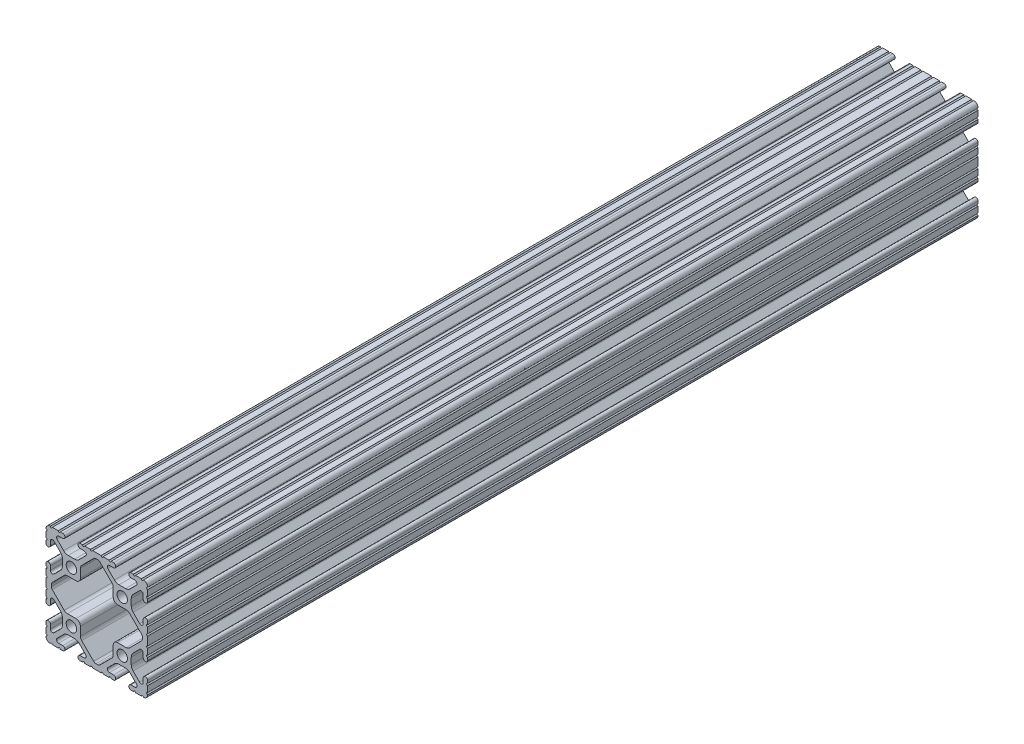
from build123d import *

# Parameters (mm, degrees)
SKETCH1_R      = 2.6035
EXTRUDE1_DEPTH = 415


with BuildPart() as part:
    # Sketch1 → Extrude1 (new body)
    with BuildSketch(Plane.XY):
        with BuildLine():
            Line((910.156254844, 557.093818315), (905.889054844, 557.093818315))
            ThreePointArc((905.889054844, 557.093818315), (905.381054844, 556.585818315), (904.873054844, 557.093818315))
            Line((904.873054844, 557.093818315), (901.926654844, 557.093818315))
            ThreePointArc((901.926654844, 557.093818315), (901.418654844, 556.585818315), (900.910654844, 557.093818315))
            Line((900.910654844, 557.093818315), (899.678754844, 557.093818315))
            ThreePointArc((899.678754844, 557.093818315), (898.573854844, 555.988918315), (899.678754844, 554.884018315))
            Line((899.678754844, 554.884018315), (901.727603922, 554.884018315))
            ThreePointArc((901.727603922, 554.884018315), (902.668315674, 554.237585095), (902.477834304, 553.112182342))
            Line((902.477834304, 553.112182342), (899.193915354, 549.828164729))
            ThreePointArc((899.193915354, 549.828164729), (898.163859528, 549.139886645), (896.948817599, 548.898195034))
            Line((896.948817599, 548.898195034), (893.696410281, 548.898195034))
            ThreePointArc((893.696410281, 548.898195034), (892.481371808, 549.139885213), (891.451317818, 549.828159437))
            Line((891.451317818, 549.828159437), (888.167597463, 553.111962966))
            ThreePointArc((888.167597463, 553.111962966), (887.978324963, 554.240284421), (888.924126242, 554.884018315))
            Line((888.924126242, 554.884018315), (890.966554844, 554.884018315))
            ThreePointArc((890.966554844, 554.884018315), (892.071454844, 555.988918315), (890.966554844, 557.093818315))
            Line((890.966554844, 557.093818315), (889.734654844, 557.093818315))
            ThreePointArc((889.734654844, 557.093818315), (889.226654844, 556.585818315), (888.718654844, 557.093818315))
            Line((888.718654844, 557.093818315), (885.772254844, 557.093818315))
            ThreePointArc((885.772254844, 557.093818315), (885.264254844, 556.585818315), (884.756254844, 557.093818315))
            Line((884.756254844, 557.093818315), (884.730854844, 557.093818315))
            ThreePointArc((884.730854844, 557.093818315), (883.240132328, 556.476340831), (882.622654844, 554.985618315))
            Line((882.622654844, 554.985618315), (882.622654844, 554.960218315))
            ThreePointArc((882.622654844, 554.960218315), (883.130654844, 554.452218315), (882.622654844, 553.944218315))
            Line((882.622654844, 553.944218315), (882.622654844, 550.997818315))
            ThreePointArc((882.622654844, 550.997818315), (883.130654844, 550.489818315), (882.622654844, 549.981818315))
            Line((882.622654844, 549.981818315), (882.622654844, 548.749918315))
            ThreePointArc((882.622654844, 548.749918315), (883.727554844, 547.645018315), (884.832454844, 548.749918315))
            Line((884.832454844, 548.749918315), (884.832454844, 550.798767394))
            ThreePointArc((884.832454844, 550.798767394), (885.478888064, 551.739479145), (886.604290816, 551.548997776))
            Line((886.604290816, 551.548997776), (889.888308429, 548.265078825))
            ThreePointArc((889.888308429, 548.265078825), (890.576586514, 547.235022999), (890.818278124, 546.01998107))
            Line((890.818278124, 546.01998107), (890.818278124, 542.767573752))
            ThreePointArc((890.818278124, 542.767573752), (890.576587946, 541.552535279), (889.888313721, 540.522481289))
            Line((889.888313721, 540.522481289), (886.604510192, 537.238760934))
            ThreePointArc((886.604510192, 537.238760934), (885.476188737, 537.049488434), (884.832454844, 537.995289713))
            Line((884.832454844, 537.995289713), (884.832454844, 540.037718315))
            ThreePointArc((884.832454844, 540.037718315), (883.727554844, 541.142618315), (882.622654844, 540.037718315))
            Line((882.622654844, 540.037718315), (882.622654844, 538.805818315))
            ThreePointArc((882.622654844, 538.805818315), (883.130654844, 538.297818315), (882.622654844, 537.789818315))
            Line((882.622654844, 537.789818315), (882.622654844, 534.843418315))
            ThreePointArc((882.622654844, 534.843418315), (883.130654844, 534.335418315), (882.622654844, 533.827418315))
            Line((882.622654844, 533.827418315), (882.622654844, 529.560218315))
            ThreePointArc((882.622654844, 529.560218315), (883.130654844, 529.052218315), (882.622654844, 528.544218315))
            Line((882.622654844, 528.544218315), (882.622654844, 525.597818315))
            ThreePointArc((882.622654844, 525.597818315), (883.130654844, 525.089818315), (882.622654844, 524.581818315))
            Line((882.622654844, 524.581818315), (882.622654844, 523.349918315))
            ThreePointArc((882.622654844, 523.349918315), (883.727554844, 522.245018315), (884.832454844, 523.349918315))
            Line((884.832454844, 523.349918315), (884.832454844, 525.398767394))
            ThreePointArc((884.832454844, 525.398767394), (885.478888064, 526.339479145), (886.604290816, 526.148997776))
            Line((886.604290816, 526.148997776), (889.888308429, 522.865078825))
            ThreePointArc((889.888308429, 522.865078825), (890.576586514, 521.835022999), (890.818278124, 520.61998107))
            Line((890.818278124, 520.61998107), (890.818278124, 517.367573752))
            ThreePointArc((890.818278124, 517.367573752), (890.576587946, 516.152535279), (889.888313721, 515.122481289))
            Line((889.888313721, 515.122481289), (886.604510192, 511.838760934))
            ThreePointArc((886.604510192, 511.838760934), (885.476188737, 511.649488434), (884.832454844, 512.595289713))
            Line((884.832454844, 512.595289713), (884.832454844, 514.637718315))
            ThreePointArc((884.832454844, 514.637718315), (883.727554844, 515.742618315), (882.622654844, 514.637718315))
            Line((882.622654844, 514.637718315), (882.622654844, 513.405818315))
            ThreePointArc((882.622654844, 513.405818315), (883.130654844, 512.897818315), (882.622654844, 512.389818315))
            Line((882.622654844, 512.389818315), (882.622654844, 509.443418315))
            ThreePointArc((882.622654844, 509.443418315), (883.130654844, 508.935418315), (882.622654844, 508.427418315))
            Line((882.622654844, 508.427418315), (882.622654844, 508.402018315))
            ThreePointArc((882.622654844, 508.402018315), (883.240132328, 506.911295799), (884.730854844, 506.293818315))
            Line((884.730854844, 506.293818315), (884.756254844, 506.293818315))
            ThreePointArc((884.756254844, 506.293818315), (885.264254844, 506.801818315), (885.772254844, 506.293818315))
            Line((885.772254844, 506.293818315), (888.718654844, 506.293818315))
            ThreePointArc((888.718654844, 506.293818315), (889.226654844, 506.801818315), (889.734654844, 506.293818315))
            Line((889.734654844, 506.293818315), (890.966554844, 506.293818315))
            ThreePointArc((890.966554844, 506.293818315), (892.071454844, 507.398718315), (890.966554844, 508.503618315))
            Line((890.966554844, 508.503618315), (888.917705765, 508.503618315))
            ThreePointArc((888.917705765, 508.503618315), (887.976994014, 509.150051535), (888.167475383, 510.275454288))
            Line((888.167475383, 510.275454288), (891.451394334, 513.5594719))
            ThreePointArc((891.451394334, 513.5594719), (892.481450159, 514.247749985), (893.696492089, 514.489441595))
            Line((893.696492089, 514.489441595), (896.948899407, 514.489441595))
            ThreePointArc((896.948899407, 514.489441595), (898.163937879, 514.247751417), (899.19399187, 513.559477193))
            Line((899.19399187, 513.559477193), (902.477712224, 510.275673663))
            ThreePointArc((902.477712224, 510.275673663), (902.666984724, 509.147352209), (901.721183446, 508.503618315))
            Line((901.721183446, 508.503618315), (899.678754844, 508.503618315))
            ThreePointArc((899.678754844, 508.503618315), (898.573854844, 507.398718315), (899.678754844, 506.293818315))
            Line((899.678754844, 506.293818315), (900.910654844, 506.293818315))
            ThreePointArc((900.910654844, 506.293818315), (901.418654844, 506.801818315), (901.926654844, 506.293818315))
            Line((901.926654844, 506.293818315), (904.873054844, 506.293818315))
            ThreePointArc((904.873054844, 506.293818315), (905.381054844, 506.801818315), (905.889054844, 506.293818315))
            Line((905.889054844, 506.293818315), (910.156254844, 506.293818315))
            ThreePointArc((910.156254844, 506.293818315), (910.664254844, 506.801818315), (911.172254844, 506.293818315))
            Line((911.172254844, 506.293818315), (914.118654844, 506.293818315))
            ThreePointArc((914.118654844, 506.293818315), (914.626654844, 506.801818315), (915.134654844, 506.293818315))
            Line((915.134654844, 506.293818315), (916.366554844, 506.293818315))
            ThreePointArc((916.366554844, 506.293818315), (917.471454844, 507.398718315), (916.366554844, 508.503618315))
            Line((916.366554844, 508.503618315), (914.317705765, 508.503618315))
            ThreePointArc((914.317705765, 508.503618315), (913.376994014, 509.150051535), (913.567475383, 510.275454288))
            Line((913.567475383, 510.275454288), (916.851394334, 513.5594719))
            ThreePointArc((916.851394334, 513.5594719), (917.881450159, 514.247749985), (919.096492089, 514.489441595))
            Line((919.096492089, 514.489441595), (922.348899407, 514.489441595))
            ThreePointArc((922.348899407, 514.489441595), (923.563937879, 514.247751417), (924.59399187, 513.559477193))
            Line((924.59399187, 513.559477193), (927.877712224, 510.275673663))
            ThreePointArc((927.877712224, 510.275673663), (928.066984724, 509.147352209), (927.121183446, 508.503618315))
            Line((927.121183446, 508.503618315), (925.078754844, 508.503618315))
            ThreePointArc((925.078754844, 508.503618315), (923.973854844, 507.398718315), (925.078754844, 506.293818315))
            Line((925.078754844, 506.293818315), (926.310654844, 506.293818315))
            ThreePointArc((926.310654844, 506.293818315), (926.818654844, 506.801818315), (927.326654844, 506.293818315))
            Line((927.326654844, 506.293818315), (930.273054844, 506.293818315))
            ThreePointArc((930.273054844, 506.293818315), (930.781054844, 506.801818315), (931.289054844, 506.293818315))
            Line((931.289054844, 506.293818315), (931.314454844, 506.293818315))
            ThreePointArc((931.314454844, 506.293818315), (932.80517736, 506.911295799), (933.422654844, 508.402018315))
            Line((933.422654844, 508.402018315), (933.422654844, 508.427418315))
            ThreePointArc((933.422654844, 508.427418315), (932.914654844, 508.935418315), (933.422654844, 509.443418315))
            Line((933.422654844, 509.443418315), (933.422654844, 512.389818315))
            ThreePointArc((933.422654844, 512.389818315), (932.914654844, 512.897818315), (933.422654844, 513.405818315))
            Line((933.422654844, 513.405818315), (933.422654844, 514.637718315))
            ThreePointArc((933.422654844, 514.637718315), (932.317754844, 515.742618315), (931.212854844, 514.637718315))
            Line((931.212854844, 514.637718315), (931.212854844, 512.588869236))
            ThreePointArc((931.212854844, 512.588869236), (930.566421623, 511.648157485), (929.441018871, 511.838638854))
            Line((929.441018871, 511.838638854), (926.157001258, 515.122557805))
            ThreePointArc((926.157001258, 515.122557805), (925.468723173, 516.15261363), (925.227031563, 517.36765556))
            Line((925.227031563, 517.36765556), (925.227031563, 520.620062878))
            ThreePointArc((925.227031563, 520.620062878), (925.468721741, 521.83510135), (926.156995966, 522.865155341))
            Line((926.156995966, 522.865155341), (929.440799495, 526.148875695))
            ThreePointArc((929.440799495, 526.148875695), (930.56912095, 526.338148196), (931.212854844, 525.392346917))
            Line((931.212854844, 525.392346917), (931.212854844, 523.349918315))
            ThreePointArc((931.212854844, 523.349918315), (932.317754844, 522.245018315), (933.422654844, 523.349918315))
            Line((933.422654844, 523.349918315), (933.422654844, 524.581818315))
            ThreePointArc((933.422654844, 524.581818315), (932.914654844, 525.089818315), (933.422654844, 525.597818315))
            Line((933.422654844, 525.597818315), (933.422654844, 528.544218315))
            ThreePointArc((933.422654844, 528.544218315), (932.914654844, 529.052218315), (933.422654844, 529.560218315))
            Line((933.422654844, 529.560218315), (933.422654844, 533.827418315))
            ThreePointArc((933.422654844, 533.827418315), (932.914654844, 534.335418315), (933.422654844, 534.843418315))
            Line((933.422654844, 534.843418315), (933.422654844, 537.789818315))
            ThreePointArc((933.422654844, 537.789818315), (932.914654844, 538.297818315), (933.422654844, 538.805818315))
            Line((933.422654844, 538.805818315), (933.422654844, 540.037718315))
            ThreePointArc((933.422654844, 540.037718315), (932.317754844, 541.142618315), (931.212854844, 540.037718315))
            Line((931.212854844, 540.037718315), (931.212854844, 537.988869236))
            ThreePointArc((931.212854844, 537.988869236), (930.566421623, 537.048157485), (929.441018871, 537.238638854))
            Line((929.441018871, 537.238638854), (926.157001258, 540.522557805))
            ThreePointArc((926.157001258, 540.522557805), (925.468723173, 541.55261363), (925.227031563, 542.76765556))
            Line((925.227031563, 542.76765556), (925.227031563, 546.020062878))
            ThreePointArc((925.227031563, 546.020062878), (925.468721741, 547.23510135), (926.156995966, 548.265155341))
            Line((926.156995966, 548.265155341), (929.440799495, 551.548875695))
            ThreePointArc((929.440799495, 551.548875695), (930.56912095, 551.738148196), (931.212854844, 550.792346917))
            Line((931.212854844, 550.792346917), (931.212854844, 548.749918315))
            ThreePointArc((931.212854844, 548.749918315), (932.317754844, 547.645018315), (933.422654844, 548.749918315))
            Line((933.422654844, 548.749918315), (933.422654844, 549.981818315))
            ThreePointArc((933.422654844, 549.981818315), (932.914654844, 550.489818315), (933.422654844, 550.997818315))
            Line((933.422654844, 550.997818315), (933.422654844, 553.944218315))
            ThreePointArc((933.422654844, 553.944218315), (932.914654844, 554.452218315), (933.422654844, 554.960218315))
            Line((933.422654844, 554.960218315), (933.422654844, 554.985618315))
            ThreePointArc((933.422654844, 554.985618315), (932.80517736, 556.476340831), (931.314454844, 557.093818315))
            Line((931.314454844, 557.093818315), (931.289054844, 557.093818315))
            ThreePointArc((931.289054844, 557.093818315), (930.781054844, 556.585818315), (930.273054844, 557.093818315))
            Line((930.273054844, 557.093818315), (927.326654844, 557.093818315))
            ThreePointArc((927.326654844, 557.093818315), (926.818654844, 556.585818315), (926.310654844, 557.093818315))
            Line((926.310654844, 557.093818315), (925.078754844, 557.093818315))
            ThreePointArc((925.078754844, 557.093818315), (923.973854844, 555.988918315), (925.078754844, 554.884018315))
            Line((925.078754844, 554.884018315), (927.127603922, 554.884018315))
            ThreePointArc((927.127603922, 554.884018315), (928.068315674, 554.237585095), (927.877834304, 553.112182342))
            Line((927.877834304, 553.112182342), (924.593915354, 549.828164729))
            ThreePointArc((924.593915354, 549.828164729), (923.563859528, 549.139886645), (922.348817599, 548.898195034))
            Line((922.348817599, 548.898195034), (919.096410281, 548.898195034))
            ThreePointArc((919.096410281, 548.898195034), (917.881371808, 549.139885213), (916.851317818, 549.828159437))
            Line((916.851317818, 549.828159437), (913.567597463, 553.111962966))
            ThreePointArc((913.567597463, 553.111962966), (913.378324963, 554.240284421), (914.324126242, 554.884018315))
            Line((914.324126242, 554.884018315), (916.366554844, 554.884018315))
            ThreePointArc((916.366554844, 554.884018315), (917.471454844, 555.988918315), (916.366554844, 557.093818315))
            Line((916.366554844, 557.093818315), (915.134654844, 557.093818315))
            ThreePointArc((915.134654844, 557.093818315), (914.626654844, 556.585818315), (914.118654844, 557.093818315))
            Line((914.118654844, 557.093818315), (911.172254844, 557.093818315))
            ThreePointArc((911.172254844, 557.093818315), (910.664254844, 556.585818315), (910.156254844, 557.093818315))
        make_face()
        with Locations((920.722654844, 518.993818315)):
            Circle(SKETCH1_R, mode=Mode.SUBTRACT)
        with Locations((895.322654844, 518.993818315)):
            Circle(SKETCH1_R, mode=Mode.SUBTRACT)
        with Locations((920.722654844, 544.393818315)):
            Circle(SKETCH1_R, mode=Mode.SUBTRACT)
        with Locations((895.322654844, 544.393818315)):
            Circle(SKETCH1_R, mode=Mode.SUBTRACT)
        with BuildLine():
            Line((930.29442333, 530.128843972), (924.31121306, 524.145453942))
            ThreePointArc((924.31121306, 524.145453942), (923.594294205, 523.666412395), (922.748625022, 523.498195034))
            Line((922.748625022, 523.498195034), (918.428078124, 523.498195034))
            ThreePointArc((918.428078124, 523.498195034), (916.865513559, 522.8509596), (916.218278124, 521.288395034))
            Line((916.218278124, 521.288395034), (916.218278124, 516.967767661))
            ThreePointArc((916.218278124, 516.967767661), (916.05006176, 516.122100884), (915.5710229, 515.405183307))
            Line((915.5710229, 515.405183307), (909.587740497, 509.422052453))
            ThreePointArc((909.587740497, 509.422052453), (909.076843497, 509.080689011), (908.474202841, 508.960818315))
            Line((908.474202841, 508.960818315), (907.571215532, 508.960818315))
            ThreePointArc((907.571215532, 508.960818315), (906.96857659, 509.080688301), (906.4576805, 509.422049828))
            Line((906.4576805, 509.422049828), (900.474290471, 515.405260099))
            ThreePointArc((900.474290471, 515.405260099), (899.995248924, 516.122178953), (899.827031563, 516.967848136))
            Line((899.827031563, 516.967848136), (899.827031563, 521.288395034))
            ThreePointArc((899.827031563, 521.288395034), (899.179796128, 522.8509596), (897.617231563, 523.498195034))
            Line((897.617231563, 523.498195034), (893.29660419, 523.498195034))
            ThreePointArc((893.29660419, 523.498195034), (892.450937413, 523.666411398), (891.734019835, 524.145450259))
            Line((891.734019835, 524.145450259), (885.750888982, 530.128732661))
            ThreePointArc((885.750888982, 530.128732661), (885.40952554, 530.639629661), (885.289654844, 531.242270317))
            Line((885.289654844, 531.242270317), (885.289654844, 532.145257627))
            ThreePointArc((885.289654844, 532.145257627), (885.409524829, 532.747896568), (885.750886357, 533.258792658))
            Line((885.750886357, 533.258792658), (891.734096627, 539.242182688))
            ThreePointArc((891.734096627, 539.242182688), (892.451015482, 539.721224235), (893.296684665, 539.889441595))
            Line((893.296684665, 539.889441595), (897.617231563, 539.889441595))
            ThreePointArc((897.617231563, 539.889441595), (899.179796128, 540.53667703), (899.827031563, 542.099241595))
            Line((899.827031563, 542.099241595), (899.827031563, 546.419868969))
            ThreePointArc((899.827031563, 546.419868969), (899.995247927, 547.265535746), (900.474286787, 547.982453323))
            Line((900.474286787, 547.982453323), (906.45756919, 553.965584176))
            ThreePointArc((906.45756919, 553.965584176), (906.96846619, 554.306947619), (907.571106846, 554.426818315))
            Line((907.571106846, 554.426818315), (908.474094155, 554.426818315))
            ThreePointArc((908.474094155, 554.426818315), (909.076733097, 554.306948329), (909.587629187, 553.965586801))
            Line((909.587629187, 553.965586801), (915.571019216, 547.982376531))
            ThreePointArc((915.571019216, 547.982376531), (916.050060763, 547.265457677), (916.218278124, 546.419788494))
            Line((916.218278124, 546.419788494), (916.218278124, 542.099241595))
            ThreePointArc((916.218278124, 542.099241595), (916.865513559, 540.53667703), (918.428078124, 539.889441595))
            Line((918.428078124, 539.889441595), (922.748705498, 539.889441595))
            ThreePointArc((922.748705498, 539.889441595), (923.594372274, 539.721225231), (924.311289852, 539.242186371))
            Line((924.311289852, 539.242186371), (930.294420705, 533.258903969))
            ThreePointArc((930.294420705, 533.258903969), (930.635784148, 532.748006969), (930.755654844, 532.145366312))
            Line((930.755654844, 532.145366312), (930.755654844, 531.242379003))
            ThreePointArc((930.755654844, 531.242379003), (930.635784858, 530.639740062), (930.29442333, 530.128843972))
        make_face(mode=Mode.SUBTRACT)
    extrude(amount=-EXTRUDE1_DEPTH)


solid = part.part
